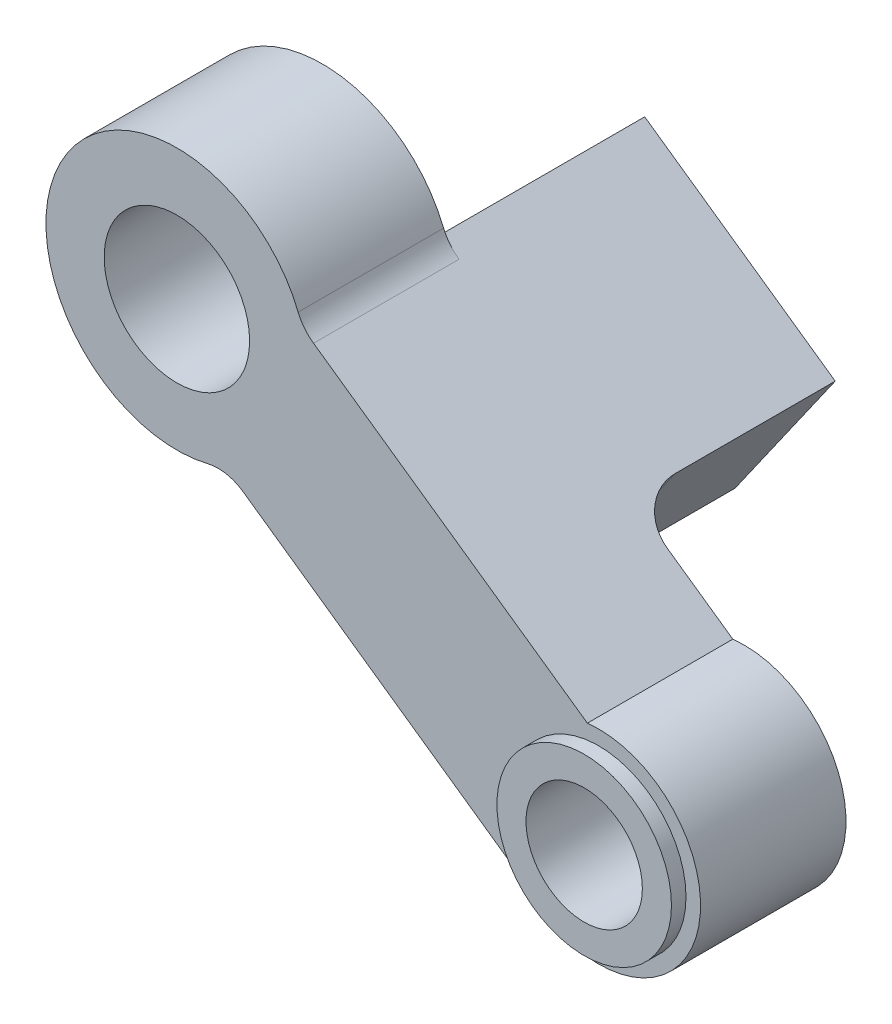
from build123d import *

# Parameters (mm, degrees)
SKETCH_4_R           = 2.0000000000000924
SKETCH_4_R_2         = 2.5
EXTRUDE_1_DEPTH      = 5
EXTRUDE_2_DEPTH      = 7
EXTRUDE_2_DEPTH_BACK = 5
FILLET_3_R           = 1.5
FILLET_4_R           = 1.5
SKETCH_6_R           = 3.0000000000000897
SKETCH_6_R_2         = 2.0000000000000884
EXTRUDE_3_DEPTH      = 0.5


with BuildPart() as part:
    # 草图4 → 凸台-拉伸1 (new body)
    with BuildSketch(Plane.XY):
        with BuildLine():
            Line((4.306700056173786, 1.3047354621350271), (14.109660641900325, -5.571834508606824))
            ThreePointArc((14.109660641900325, -5.571834508606824), (17.74630975952625, -10.35823275650958), (11.807053976651485, -11.285630048852315))
            Line((11.807053976651485, -11.285630048852315), (1.6735833284293933, -4.177214244302438))
            ThreePointArc((1.6735833284293933, -4.177214244302438), (-4.056339542742652, 1.948360724810045), (4.306700056173786, 1.3047354621350271))
        make_face()
        with Locations((14.500000000000004, -9.05)):
            Circle(SKETCH_4_R, mode=Mode.SUBTRACT)
        Circle(SKETCH_4_R_2, mode=Mode.SUBTRACT)
    extrude(amount=EXTRUDE_1_DEPTH)

    # 草图5 → 凸台-拉伸2 (add, two sides: drawn at the far end of the back side and taken through both)
    with BuildSketch(Plane(origin=(0, 0, 0), x_dir=(-1, 0, 0), z_dir=(0, 0, -1)).offset(-EXTRUDE_2_DEPTH_BACK)):
        Polygon((-0.6347261790104263, -3.4484778778636556), (-7.184027973017892, -8.042674870920285), (-10.629675717810366, -3.130698525414685), (-4.080373923802897, 1.463498467641941), align=None)
    extrude(amount=EXTRUDE_2_DEPTH + EXTRUDE_2_DEPTH_BACK)

    # 圆角3
    fillet_3_edges = [part.edges().sort_by_distance(p)[0] for p in [
        (8.90685184541413, -5.586686698167485, 0),
        (4.306700056173785, 1.3047354621350273, 2.5),
    ]]
    fillet(fillet_3_edges, radius=FILLET_3_R)

    # 圆角4
    fillet_4_edges = [part.edges().sort_by_distance(p)[0] for p in [
        (11.807053976651485, -11.285630048852315, 2.5),
        (1.6735833284293933, -4.177214244302439, 2.5),
    ]]
    fillet(fillet_4_edges, radius=FILLET_4_R)

    # 草图6 → 凸台-拉伸3 (add)
    with BuildSketch(Plane.XY.offset(5)):
        with Locations((14.500000000000004, -9.05)):
            Circle(SKETCH_6_R)
        with Locations((14.500000000000004, -9.05)):
            Circle(SKETCH_6_R_2, mode=Mode.SUBTRACT)
    extrude(amount=EXTRUDE_3_DEPTH)


solid = part.part
